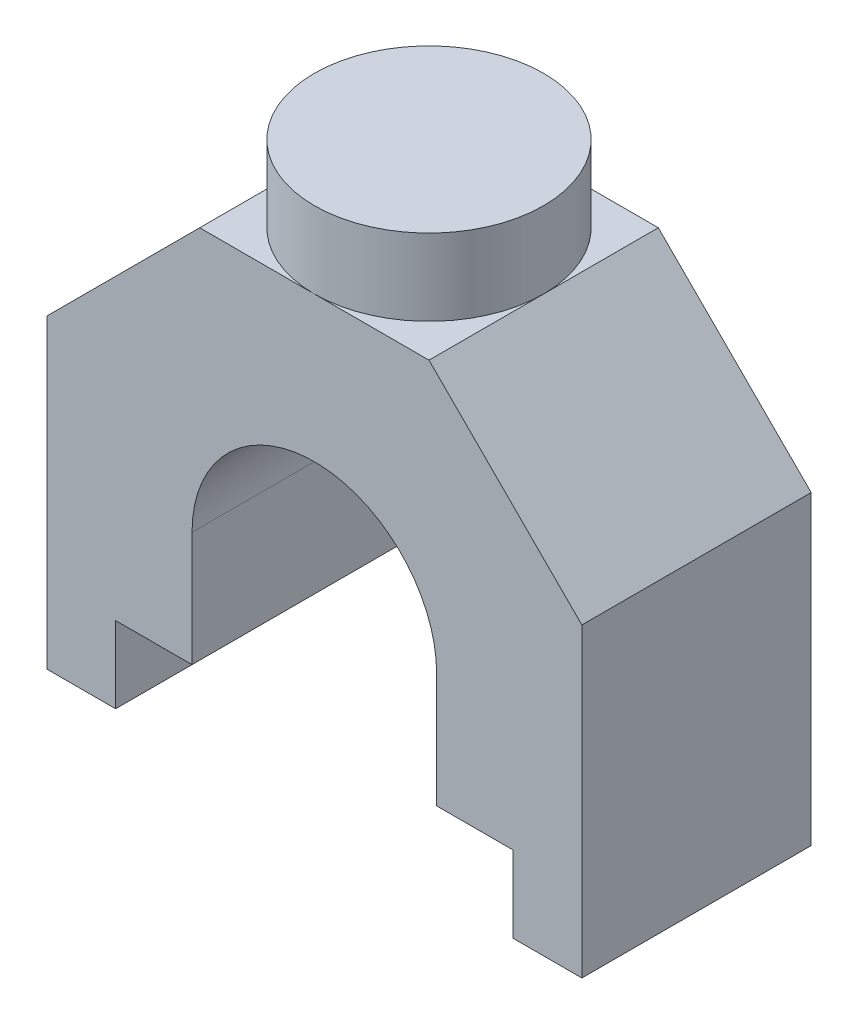
from build123d import *

# Parameters (mm, degrees)
EXTRUDE_1_DEPTH     = 3
SKETCH_4_R          = 1.5
EXTRUDE_3_DEPTH     = 1
SKETCH_8_W          = 1.758290516
SKETCH_8_H          = 4.288229266
SKETCH_8_W_2        = 1.505617074
SKETCH_8_H_2        = 4.786356908
CUT_EXTRUDE_3_DEPTH = 1


with BuildPart() as part:
    # 草图2 → 凸台-拉伸1 (new body)
    with BuildSketch(Plane.XY):
        with BuildLine():
            Line((5, 0), (2, 0))
            Line((2, 0), (0, -2))
            Line((0, -2), (0, -6))
            Line((0, -6), (1.9, -6))
            Line((1.9, -6), (1.9, -3.5))
            ThreePointArc((1.9, -3.5), (3.5, -1.9), (5.1, -3.5))
            Line((5.1, -3.5), (5.1, -6))
            Line((5.1, -6), (7, -6))
            Line((7, -6), (7, -2))
            Line((7, -2), (5, 0))
        make_face()
    extrude(amount=EXTRUDE_1_DEPTH)

    # 草图4 → 凸台-拉伸3 (add)
    with BuildSketch(Plane(origin=(0, 0, 0), x_dir=(1, 0, 0), z_dir=(0, 1, 0))):
        with Locations(Location((3.5, -1.5, 0), (0, 0, 270))):  # turned: the seam where the file's is
            Circle(SKETCH_4_R)
    extrude(amount=EXTRUDE_3_DEPTH)

    # 草图8 → 切除-拉伸3 (cut)
    with BuildSketch(Plane.XZ.offset(6)):
        with Locations((1.779145258, 1.583021274)):
            Rectangle(SKETCH_8_W, SKETCH_8_H)
        with Locations((5.347191463, 1.528876965)):
            Rectangle(SKETCH_8_W_2, SKETCH_8_H_2)
    extrude(amount=-CUT_EXTRUDE_3_DEPTH, mode=Mode.SUBTRACT)


solid = part.part
